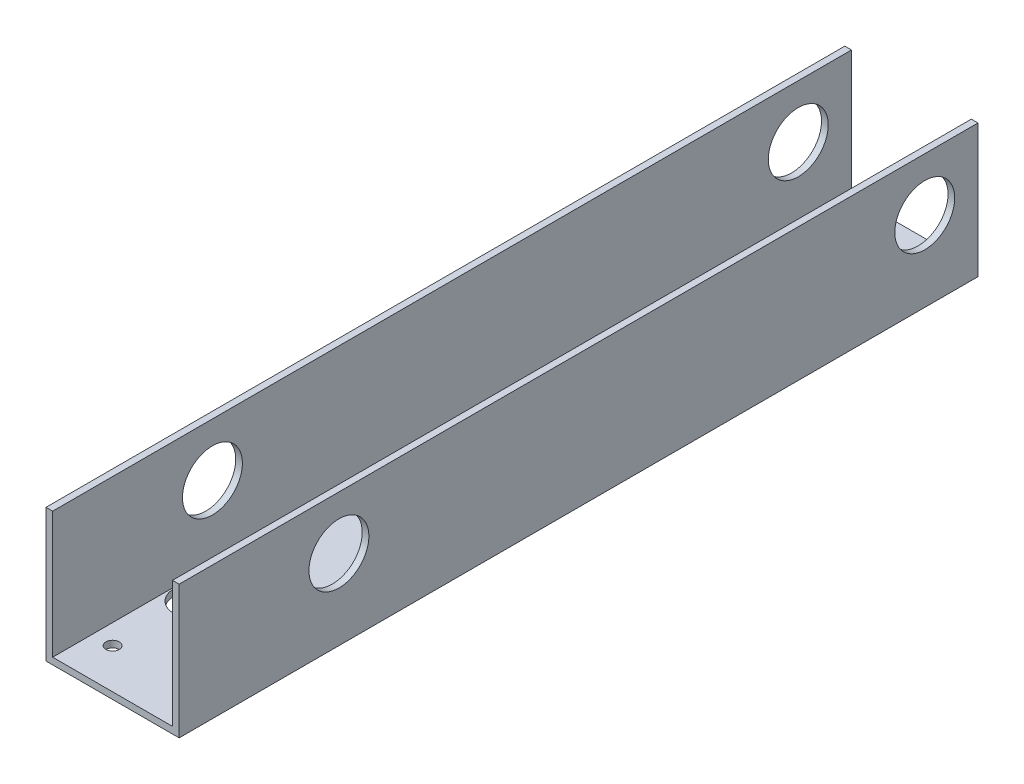
from build123d import *

# Parameters (mm, degrees)
BOSS_EXTRUDE1_DEPTH     = 381
CUT_EXTRUDE1_DEPTH      = 392.440289189
CUT_EXTRUDE1_DEPTH_BACK = 392.440289189
SKETCH2_R               = 3.175
CUT_EXTRUDE3_DEPTH      = 12.7
CUT_EXTRUDE4_DEPTH      = 390.418118351
CUT_EXTRUDE4_DEPTH_BACK = 390.418118351
SKETCH7_R               = 14.2875
CUT_EXTRUDE5_DEPTH      = 392.440289189
CUT_EXTRUDE5_DEPTH_BACK = 392.440289189
SKETCH8_R               = 3.175
SKETCH9_R               = 14.2875
CUT_EXTRUDE6_DEPTH      = 152.4


with BuildPart() as part:
    # Sketch1 → Boss-Extrude1 (new body)
    with BuildSketch(Plane.XY):
        Polygon((0, 0), (63.5, 0), (63.5, 63.5), (60.325, 63.5), (60.325, 3.175), (3.175, 3.175), (3.175, 63.5), (0, 63.5), align=None)
    extrude(amount=BOSS_EXTRUDE1_DEPTH)

    # Sketch2 → Cut-Extrude1 (cut, two sides: drawn at the far end of the back side and taken through both)
    with BuildSketch(Plane.XZ.offset(-CUT_EXTRUDE1_DEPTH_BACK)):
        with Locations((12.7, 361.95)):
            Circle(SKETCH2_R)
        with Locations((50.8, 361.95)):
            Circle(SKETCH2_R)
        with Locations((12.7, 57.15)):
            Circle(SKETCH2_R)
        with Locations((12.7, 133.35)):
            Circle(SKETCH2_R)
        with Locations((12.7, 209.55)):
            Circle(SKETCH2_R)
    extrude(amount=CUT_EXTRUDE1_DEPTH + CUT_EXTRUDE1_DEPTH_BACK, mode=Mode.SUBTRACT)

    # Sketch4 → Cut-Extrude3 (cut)
    with BuildSketch(Plane.XZ):
        with BuildLine():
            Line((24.13, 323.85), (24.13, 285.75))
            ThreePointArc((24.13, 285.75), (13.97, 275.59), (3.81, 285.75))
            Line((3.81, 285.75), (3.81, 323.85))
            ThreePointArc((3.81, 323.85), (13.97, 334.01), (24.13, 323.85))
        make_face()
    extrude(amount=-CUT_EXTRUDE3_DEPTH, mode=Mode.SUBTRACT)

    # Sketch7 → Cut-Extrude4 (cut, two sides: drawn at the far end of the back side and taken through both)
    with BuildSketch(Plane.ZY.offset(-13.97).offset(-CUT_EXTRUDE4_DEPTH_BACK)):
        with Locations((304.8, 38.1)):
            Circle(SKETCH7_R)
    extrude(amount=CUT_EXTRUDE4_DEPTH + CUT_EXTRUDE4_DEPTH_BACK, mode=Mode.SUBTRACT)

    # Sketch8 → Cut-Extrude5 (cut, two sides: drawn at the far end of the back side and taken through both)
    with BuildSketch(Plane.XZ.offset(-CUT_EXTRUDE5_DEPTH_BACK)):
        with Locations((38.735, 304.8)):
            Circle(SKETCH8_R)
        with Locations((53.975, 316.23)):
            Circle(SKETCH8_R)
        with Locations((53.975, 293.37)):
            Circle(SKETCH8_R)
    extrude(amount=CUT_EXTRUDE5_DEPTH + CUT_EXTRUDE5_DEPTH_BACK, mode=Mode.SUBTRACT)

    # Sketch9 → Cut-Extrude6 (cut)
    with BuildSketch(Plane.ZY):
        with Locations((25.4, 38.1)):
            Circle(SKETCH9_R)
    extrude(amount=-CUT_EXTRUDE6_DEPTH, mode=Mode.SUBTRACT)


solid = part.part
